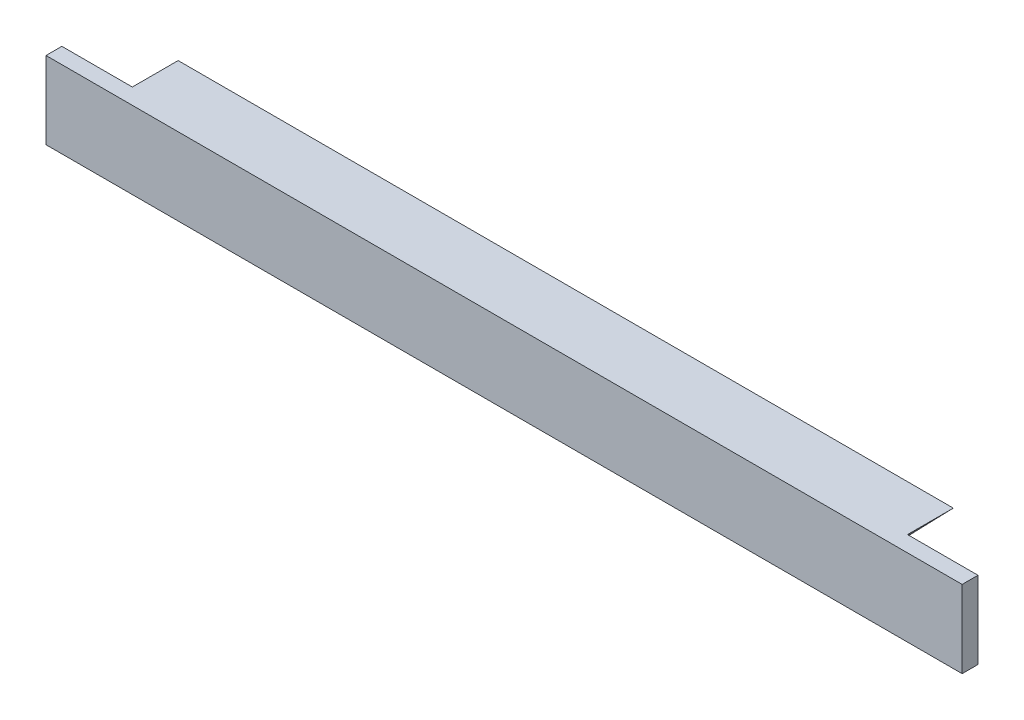
from build123d import *

# Parameters (mm, degrees)
Y_KSEKLIK_EKSTR_ZYON1_DEPTH = 2.6
IZIM2_W                     = 52
IZIM2_H                     = 4.388233566
Y_KSEKLIK_EKSTR_ZYON3_DEPTH = 0.9


with BuildPart() as part:
    # Çizim1 → Yükseklik-Ekstrüzyon1 (new body)
    with BuildSketch(Plane.XY):
        with BuildLine():
            Line((22, 4.388233566), (18.634136343, 0.912893359))
            ThreePointArc((18.634136343, 0.912893359), (17.649333458, 0.237635078), (16.479145422, 0))
            Line((16.479145422, 0), (-16.479145422, 0))
            ThreePointArc((-16.479145422, 0), (-17.649333458, 0.237635078), (-18.634136343, 0.912893359))
            Line((-18.634136343, 0.912893359), (-22, 4.388233566))
            Line((-22, 4.388233566), (22, 4.388233566))
        make_face()
    extrude(amount=Y_KSEKLIK_EKSTR_ZYON1_DEPTH)

    # Çizim2 → Yükseklik-Ekstrüzyon3 (add)
    with BuildSketch(Plane.XY.offset(2.6)):
        with Locations((0, 2.194116783)):
            Rectangle(IZIM2_W, IZIM2_H)
    extrude(amount=Y_KSEKLIK_EKSTR_ZYON3_DEPTH)


solid = part.part
